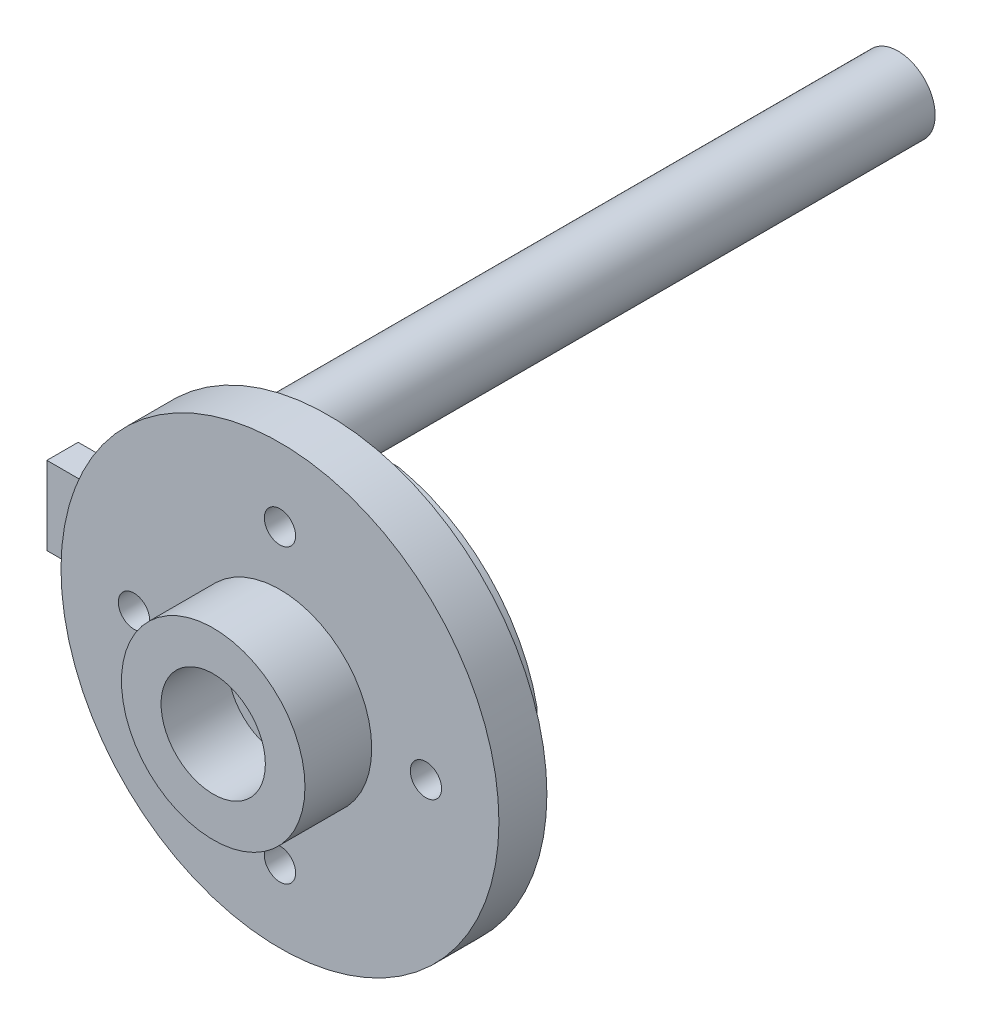
from build123d import *

# Parameters (mm, degrees)
SKETCH1_R           = 10.5
BOSS_EXTRUDE1_DEPTH = 2.3
SKETCH2_R           = 0.75
CUT_EXTRUDE1_DEPTH  = 16.026310259
SKETCH3_R           = 1.5
CUT_EXTRUDE2_DEPTH  = 2.3
CIRPATTERN1_COUNT   = 4
SKETCH4_R           = 4.4
SKETCH4_R_2         = 2.5
BOSS_EXTRUDE2_DEPTH = 3.2
SKETCH5_W           = 22
SKETCH5_H           = 3.75
SKETCH5_R           = 0.75
SKETCH5_R_2         = 1.5
BOSS_EXTRUDE3_DEPTH = 1.5
SKETCH6_R           = 1.778
BOSS_EXTRUDE4_DEPTH = 36
SKETCH7_W           = 3.75
SKETCH7_H           = 6.6491
SKETCH7_R           = 0.75
BOSS_EXTRUDE5_DEPTH = 1.5


with BuildPart() as part:
    # Sketch1 → Boss-Extrude1 (new body)
    with BuildSketch(Plane.XY):
        Circle(SKETCH1_R)
    extrude(amount=BOSS_EXTRUDE1_DEPTH)

    # Sketch2 → Cut-Extrude1 (cut, through all)
    with BuildSketch(Plane.XY.offset(2.3)):
        with Locations((0, 7)):
            Circle(SKETCH2_R)
    cut_extrude1 = extrude(amount=-CUT_EXTRUDE1_DEPTH, mode=Mode.SUBTRACT)

    # Sketch3 → Cut-Extrude2 (cut)
    with BuildSketch(Plane.XY.offset(2.3)):
        Circle(SKETCH3_R)
    extrude(amount=-CUT_EXTRUDE2_DEPTH, mode=Mode.SUBTRACT)

    # CirPattern1: Cut-Extrude1 ×4 about axis
    cirpattern1_axis = Axis((0, 0, 0), (0, 0, 1))
    for i in range(1, CIRPATTERN1_COUNT):
        add(cut_extrude1.rotate(cirpattern1_axis, i * 360 / CIRPATTERN1_COUNT), mode=Mode.SUBTRACT)

    # Sketch4 → Boss-Extrude2 (add)
    with BuildSketch(Plane.XY.offset(2.3)):
        Circle(SKETCH4_R)
        Circle(SKETCH4_R_2, mode=Mode.SUBTRACT)
    extrude(amount=BOSS_EXTRUDE2_DEPTH)

    # Sketch5 → Boss-Extrude3 (add)
    with BuildSketch(Plane(origin=(0, 0, 0), x_dir=(-1, 0, 0), z_dir=(0, 0, -1))):
        with Locations((2.475846117, 0)):
            Rectangle(SKETCH5_W, SKETCH5_H)
        with Locations(Location((7, 0, 0), (0, 0, 90))):
            Circle(SKETCH5_R, mode=Mode.SUBTRACT)
        with Locations(Location((-7, 0, 0), (0, 0, 270))):
            Circle(SKETCH5_R, mode=Mode.SUBTRACT)
        with Locations(Location((0, 0, 0), (0, 0, 180))):
            Circle(SKETCH5_R_2, mode=Mode.SUBTRACT)
    extrude(amount=BOSS_EXTRUDE3_DEPTH)

    # Sketch6 → Boss-Extrude4 (add)
    with BuildSketch(Plane(origin=(0, 0, -1.5), x_dir=(-1, 0, 0), z_dir=(0, 0, -1))):
        with Locations((10.16, 0)):
            Circle(SKETCH6_R)
    extrude(amount=BOSS_EXTRUDE4_DEPTH)

    # Sketch7 → Boss-Extrude5 (add)
    with BuildSketch(Plane(origin=(0, 0, 0), x_dir=(-1, 0, 0), z_dir=(0, 0, -1))):
        with BuildLine():
            Line((-8.524153883, 1.875), (-1.875, 1.875))
            Line((-1.875, 1.875), (-1.875, 8.5241))
            ThreePointArc((-1.875, 8.5241), (-6.199356528, 6.199337688), (-8.524153883, 1.875))
        make_face()
        with BuildLine():
            Line((1.875, 8.5241), (1.875, 1.875))
            Line((1.875, 1.875), (8.5241, 1.875))
            ThreePointArc((8.5241, 1.875), (6.199324729, 6.199324729), (1.875, 8.5241))
        make_face()
        with BuildLine():
            Line((-1.875, -8.5241), (-1.875, -1.875))
            Line((-1.875, -1.875), (-8.524153883, -1.875))
            ThreePointArc((-8.524153883, -1.875), (-6.199356528, -6.199337688), (-1.875, -8.5241))
        make_face()
        with BuildLine():
            Line((8.5241, -1.875), (1.875, -1.875))
            Line((1.875, -1.875), (1.875, -8.5241))
            ThreePointArc((1.875, -8.5241), (6.199324729, -6.199324729), (8.5241, -1.875))
        make_face()
        with Locations((0, -5.19955)):
            Rectangle(SKETCH7_W, SKETCH7_H)
        with Locations((0, -7)):
            Circle(SKETCH7_R, mode=Mode.SUBTRACT)
        with Locations((0, 5.19955)):
            Rectangle(SKETCH7_W, SKETCH7_H)
        with Locations(Location((0, 7, 0), (0, 0, 180))):
            Circle(SKETCH7_R, mode=Mode.SUBTRACT)
    extrude(amount=BOSS_EXTRUDE5_DEPTH)


solid = part.part
